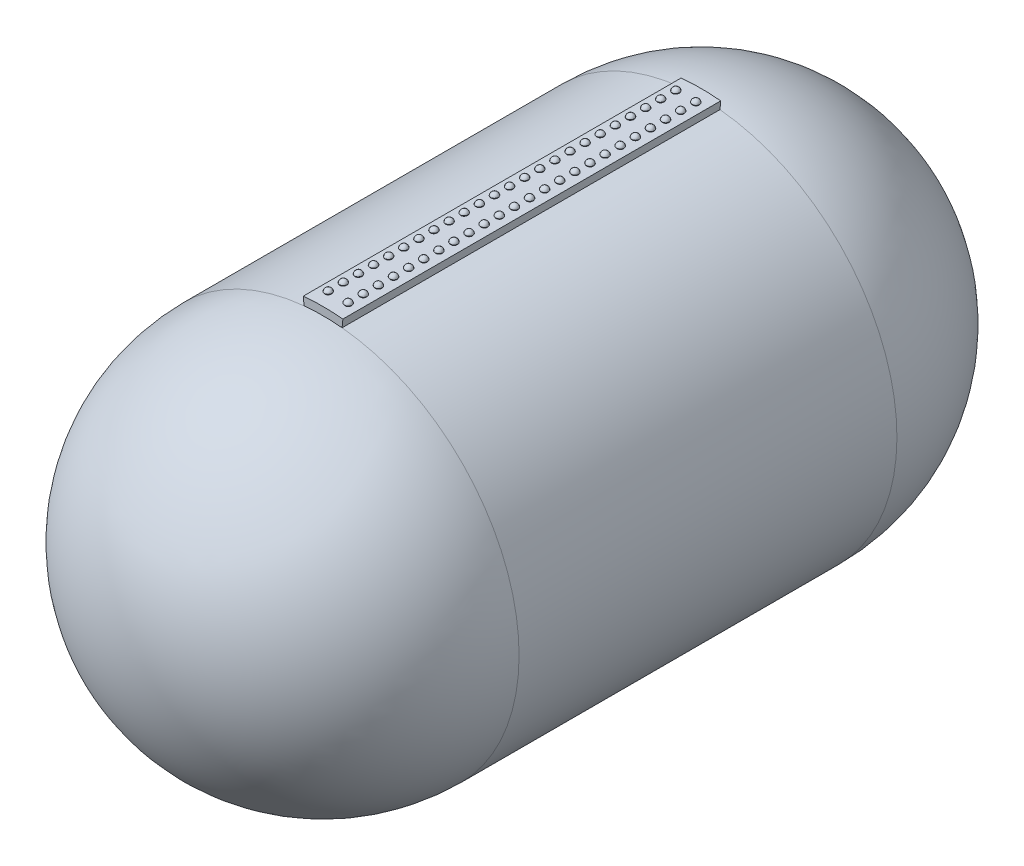
from build123d import *

# Parameters (mm, degrees)
SKETCH1_R           = 1200
BOSS_EXTRUDE1_DEPTH = 2400
LPATTERN1_COUNT     = 24
LPATTERN1_PITCH     = 96
LPATTERN2_COUNT     = 24
LPATTERN2_PITCH     = 96


with BuildPart() as part:
    # Sketch1 → Boss-Extrude1 (new body)
    with BuildSketch(Plane.XY):
        with BuildLine():
            ThreePointArc((125.801598419, 1289.87982302), (0, 1296), (-125.801598419, 1289.87982302))
            Line((-125.801598419, 1289.87982302), (-120.851072555, 1239.120663318))
            ThreePointArc((-120.851072555, 1239.120663318), (0, -1245), (120.851072555, 1239.120663318))
            Line((120.851072555, 1239.120663318), (125.801598419, 1289.87982302))
        make_face()
        Circle(SKETCH1_R, mode=Mode.SUBTRACT)
    extrude(amount=BOSS_EXTRUDE1_DEPTH)

    # Sketch7 → Revolve3 (revolve)
    with BuildSketch(Plane(origin=(0, 0, 0), x_dir=(0, 0, -1), z_dir=(1, 0, 0))):
        with BuildLine():
            Line((0, 0), (0, -1245))
            ThreePointArc((0, -1245), (880.347942577, -880.347942577), (1245, 0))
            Line((1245, 0), (0, 0))
        make_face()
    revolve3 = revolve(axis=Axis((0, 0, 0), (0, 0, -1)))

    # Mirror2: Revolve3 across plane
    add(revolve3.mirror(Plane.XY.offset(1200)))


with BuildPart() as body_2:
    # Sketch4 → Revolve1 (revolve)
    with BuildSketch(Plane.XY.offset(96)):
        Polygon((-62.97519101, 1294.46905151), (-83.950383974, 1293.448620174), (-87.233000134, 1298.545131839), (-63.230298844, 1299.712849751), align=None)
    revolve(axis=Axis((-62.97519101, 1294.46905151, 96), (0.048591968, -0.998818713, 0)))

    # Sketch6 → Revolve2 (revolve)
    with BuildSketch(Plane.XY.offset(96)):
        with BuildLine():
            Line((-39.227597554, 1300.880567664), (-63.230298844, 1299.712849751))
            Line((-63.230298844, 1299.712849751), (-64.211630785, 1319.884345956))
            ThreePointArc((-64.211630785, 1319.884345956), (-48.257154892, 1314.93450937), (-39.227597554, 1300.880567664))
        make_face()
    revolve(axis=Axis((-63.230298844, 1299.712849751, 96), (-0.048591968, 0.998818713, 0)))


with BuildPart() as body_3:
    # Mirror1: mirrored copy
    add(body_2.part.mirror(Plane(origin=(0, 0, 0), x_dir=(0, 0, 1), z_dir=(1, 0, 0))))


with BuildPart() as lpattern1_1:
    # LPattern1: pattern copy
    add(body_2.part.moved(Location(Vector(0, 0, 1) * (1 * LPATTERN1_PITCH))))


with BuildPart() as lpattern1_2:
    # LPattern1: pattern copy
    add(body_2.part.moved(Location(Vector(0, 0, 1) * (2 * LPATTERN1_PITCH))))


with BuildPart() as lpattern1_3:
    # LPattern1: pattern copy
    add(body_2.part.moved(Location(Vector(0, 0, 1) * (3 * LPATTERN1_PITCH))))


with BuildPart() as lpattern1_4:
    # LPattern1: pattern copy
    add(body_2.part.moved(Location(Vector(0, 0, 1) * (4 * LPATTERN1_PITCH))))


with BuildPart() as lpattern1_5:
    # LPattern1: pattern copy
    add(body_2.part.moved(Location(Vector(0, 0, 1) * (5 * LPATTERN1_PITCH))))


with BuildPart() as lpattern1_6:
    # LPattern1: pattern copy
    add(body_2.part.moved(Location(Vector(0, 0, 1) * (6 * LPATTERN1_PITCH))))


with BuildPart() as lpattern1_7:
    # LPattern1: pattern copy
    add(body_2.part.moved(Location(Vector(0, 0, 1) * (7 * LPATTERN1_PITCH))))


with BuildPart() as lpattern1_8:
    # LPattern1: pattern copy
    add(body_2.part.moved(Location(Vector(0, 0, 1) * (8 * LPATTERN1_PITCH))))


with BuildPart() as lpattern1_9:
    # LPattern1: pattern copy
    add(body_2.part.moved(Location(Vector(0, 0, 1) * (9 * LPATTERN1_PITCH))))


with BuildPart() as lpattern1_10:
    # LPattern1: pattern copy
    add(body_2.part.moved(Location(Vector(0, 0, 1) * (10 * LPATTERN1_PITCH))))


with BuildPart() as lpattern1_11:
    # LPattern1: pattern copy
    add(body_2.part.moved(Location(Vector(0, 0, 1) * (11 * LPATTERN1_PITCH))))


with BuildPart() as lpattern1_12:
    # LPattern1: pattern copy
    add(body_2.part.moved(Location(Vector(0, 0, 1) * (12 * LPATTERN1_PITCH))))


with BuildPart() as lpattern1_13:
    # LPattern1: pattern copy
    add(body_2.part.moved(Location(Vector(0, 0, 1) * (13 * LPATTERN1_PITCH))))


with BuildPart() as lpattern1_14:
    # LPattern1: pattern copy
    add(body_2.part.moved(Location(Vector(0, 0, 1) * (14 * LPATTERN1_PITCH))))


with BuildPart() as lpattern1_15:
    # LPattern1: pattern copy
    add(body_2.part.moved(Location(Vector(0, 0, 1) * (15 * LPATTERN1_PITCH))))


with BuildPart() as lpattern1_16:
    # LPattern1: pattern copy
    add(body_2.part.moved(Location(Vector(0, 0, 1) * (16 * LPATTERN1_PITCH))))


with BuildPart() as lpattern1_17:
    # LPattern1: pattern copy
    add(body_2.part.moved(Location(Vector(0, 0, 1) * (17 * LPATTERN1_PITCH))))


with BuildPart() as lpattern1_18:
    # LPattern1: pattern copy
    add(body_2.part.moved(Location(Vector(0, 0, 1) * (18 * LPATTERN1_PITCH))))


with BuildPart() as lpattern1_19:
    # LPattern1: pattern copy
    add(body_2.part.moved(Location(Vector(0, 0, 1) * (19 * LPATTERN1_PITCH))))


with BuildPart() as lpattern1_20:
    # LPattern1: pattern copy
    add(body_2.part.moved(Location(Vector(0, 0, 1) * (20 * LPATTERN1_PITCH))))


with BuildPart() as lpattern1_21:
    # LPattern1: pattern copy
    add(body_2.part.moved(Location(Vector(0, 0, 1) * (21 * LPATTERN1_PITCH))))


with BuildPart() as lpattern1_22:
    # LPattern1: pattern copy
    add(body_2.part.moved(Location(Vector(0, 0, 1) * (22 * LPATTERN1_PITCH))))


with BuildPart() as lpattern1_23:
    # LPattern1: pattern copy
    add(body_2.part.moved(Location(Vector(0, 0, 1) * (23 * LPATTERN1_PITCH))))


with BuildPart() as lpattern2_1:
    # LPattern2: pattern copy
    add(body_3.part.moved(Location(Vector(0, 0, 1) * (1 * LPATTERN2_PITCH))))


with BuildPart() as lpattern2_2:
    # LPattern2: pattern copy
    add(body_3.part.moved(Location(Vector(0, 0, 1) * (2 * LPATTERN2_PITCH))))


with BuildPart() as lpattern2_3:
    # LPattern2: pattern copy
    add(body_3.part.moved(Location(Vector(0, 0, 1) * (3 * LPATTERN2_PITCH))))


with BuildPart() as lpattern2_4:
    # LPattern2: pattern copy
    add(body_3.part.moved(Location(Vector(0, 0, 1) * (4 * LPATTERN2_PITCH))))


with BuildPart() as lpattern2_5:
    # LPattern2: pattern copy
    add(body_3.part.moved(Location(Vector(0, 0, 1) * (5 * LPATTERN2_PITCH))))


with BuildPart() as lpattern2_6:
    # LPattern2: pattern copy
    add(body_3.part.moved(Location(Vector(0, 0, 1) * (6 * LPATTERN2_PITCH))))


with BuildPart() as lpattern2_7:
    # LPattern2: pattern copy
    add(body_3.part.moved(Location(Vector(0, 0, 1) * (7 * LPATTERN2_PITCH))))


with BuildPart() as lpattern2_8:
    # LPattern2: pattern copy
    add(body_3.part.moved(Location(Vector(0, 0, 1) * (8 * LPATTERN2_PITCH))))


with BuildPart() as lpattern2_9:
    # LPattern2: pattern copy
    add(body_3.part.moved(Location(Vector(0, 0, 1) * (9 * LPATTERN2_PITCH))))


with BuildPart() as lpattern2_10:
    # LPattern2: pattern copy
    add(body_3.part.moved(Location(Vector(0, 0, 1) * (10 * LPATTERN2_PITCH))))


with BuildPart() as lpattern2_11:
    # LPattern2: pattern copy
    add(body_3.part.moved(Location(Vector(0, 0, 1) * (11 * LPATTERN2_PITCH))))


with BuildPart() as lpattern2_12:
    # LPattern2: pattern copy
    add(body_3.part.moved(Location(Vector(0, 0, 1) * (12 * LPATTERN2_PITCH))))


with BuildPart() as lpattern2_13:
    # LPattern2: pattern copy
    add(body_3.part.moved(Location(Vector(0, 0, 1) * (13 * LPATTERN2_PITCH))))


with BuildPart() as lpattern2_14:
    # LPattern2: pattern copy
    add(body_3.part.moved(Location(Vector(0, 0, 1) * (14 * LPATTERN2_PITCH))))


with BuildPart() as lpattern2_15:
    # LPattern2: pattern copy
    add(body_3.part.moved(Location(Vector(0, 0, 1) * (15 * LPATTERN2_PITCH))))


with BuildPart() as lpattern2_16:
    # LPattern2: pattern copy
    add(body_3.part.moved(Location(Vector(0, 0, 1) * (16 * LPATTERN2_PITCH))))


with BuildPart() as lpattern2_17:
    # LPattern2: pattern copy
    add(body_3.part.moved(Location(Vector(0, 0, 1) * (17 * LPATTERN2_PITCH))))


with BuildPart() as lpattern2_18:
    # LPattern2: pattern copy
    add(body_3.part.moved(Location(Vector(0, 0, 1) * (18 * LPATTERN2_PITCH))))


with BuildPart() as lpattern2_19:
    # LPattern2: pattern copy
    add(body_3.part.moved(Location(Vector(0, 0, 1) * (19 * LPATTERN2_PITCH))))


with BuildPart() as lpattern2_20:
    # LPattern2: pattern copy
    add(body_3.part.moved(Location(Vector(0, 0, 1) * (20 * LPATTERN2_PITCH))))


with BuildPart() as lpattern2_21:
    # LPattern2: pattern copy
    add(body_3.part.moved(Location(Vector(0, 0, 1) * (21 * LPATTERN2_PITCH))))


with BuildPart() as lpattern2_22:
    # LPattern2: pattern copy
    add(body_3.part.moved(Location(Vector(0, 0, 1) * (22 * LPATTERN2_PITCH))))


with BuildPart() as lpattern2_23:
    # LPattern2: pattern copy
    add(body_3.part.moved(Location(Vector(0, 0, 1) * (23 * LPATTERN2_PITCH))))


solid = Compound([part.part, body_2.part, body_3.part, lpattern1_1.part, lpattern1_2.part, lpattern1_3.part, lpattern1_4.part, lpattern1_5.part, lpattern1_6.part, lpattern1_7.part, lpattern1_8.part, lpattern1_9.part, lpattern1_10.part, lpattern1_11.part, lpattern1_12.part, lpattern1_13.part, lpattern1_14.part, lpattern1_15.part, lpattern1_16.part, lpattern1_17.part, lpattern1_18.part, lpattern1_19.part, lpattern1_20.part, lpattern1_21.part, lpattern1_22.part, lpattern1_23.part, lpattern2_1.part, lpattern2_2.part, lpattern2_3.part, lpattern2_4.part, lpattern2_5.part, lpattern2_6.part, lpattern2_7.part, lpattern2_8.part, lpattern2_9.part, lpattern2_10.part, lpattern2_11.part, lpattern2_12.part, lpattern2_13.part, lpattern2_14.part, lpattern2_15.part, lpattern2_16.part, lpattern2_17.part, lpattern2_18.part, lpattern2_19.part, lpattern2_20.part, lpattern2_21.part, lpattern2_22.part, lpattern2_23.part])
